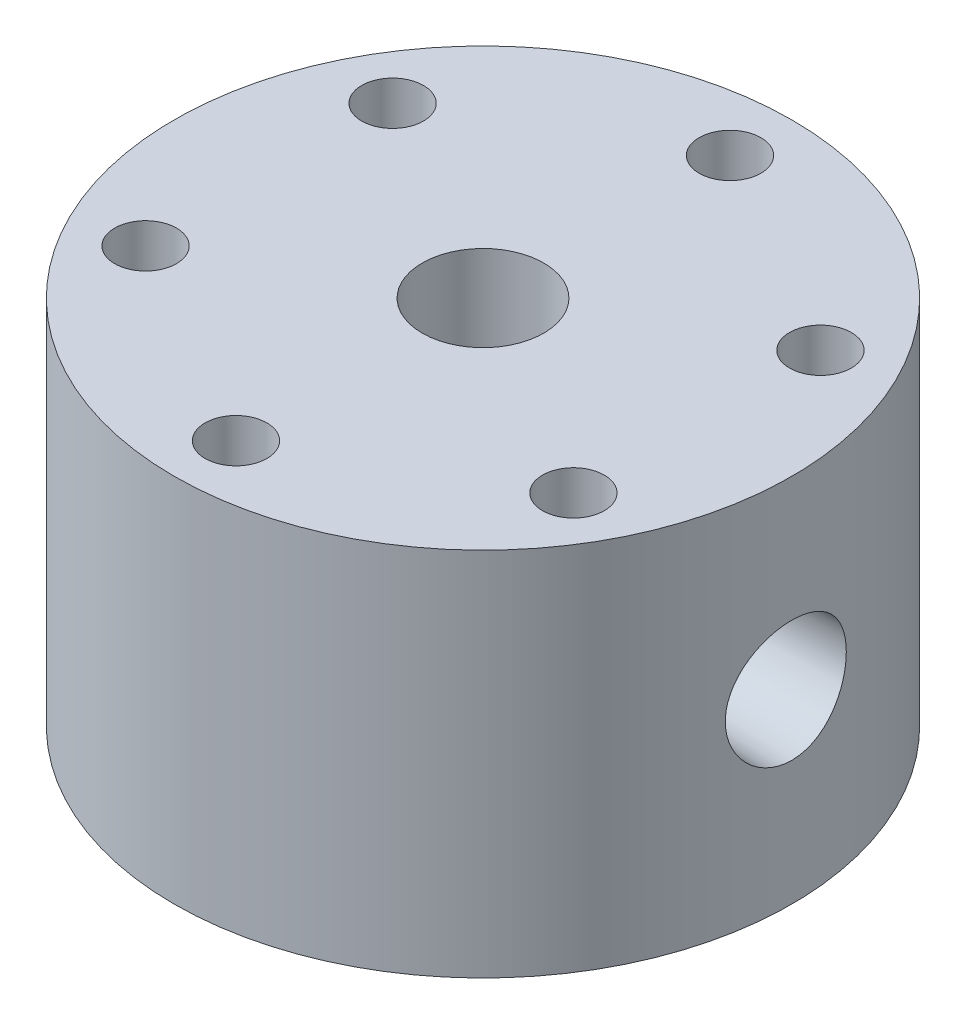
from build123d import *

# Parameters (mm, degrees)
M14X1_5_TAPPED_HOLE1_D              = 12.5
M14X1_5_TAPPED_HOLE1_DEPTH          = 25.4
M14X1_5_TAPPED_HOLE1_TIP            = 3.755378869
F_1_16_0_0625_DIAMETER_HOLE1_D      = 1.5875
F_1_16_0_0625_DIAMETER_HOLE1_DEPTH  = 28.575
F_1_16_0_0625_DIAMETER_HOLE1_TIP    = 0.476933116
F_3_32_0_09375_DIAMETER_HOLE1_D     = 2.38125
F_3_32_0_09375_DIAMETER_HOLE1_DEPTH = 28.702
F_3_32_0_09375_DIAMETER_HOLE1_TIP   = 0.715399675
F_1_4_0_25_DIAMETER_HOLE1_D         = 6.35
CIRPATTERN1_COUNT                   = 6
F_1_32_0_03125_DIAMETER_HOLE1_D     = 0.79375
F_1_32_0_03125_DIAMETER_HOLE1_DEPTH = 28.575
F_1_32_0_03125_DIAMETER_HOLE1_TIP   = 0.238466558


with BuildPart() as part:
    # Sketch1 → Revolve1 (revolve)
    with BuildSketch(Plane.XY):
        Polygon((-12.7, 0), (-31.75, 0), (-31.75, 38.1), (-3.81, 38.1), (-3.81, 6.35), (-8.0645, 6.35), (-8.0645, 8.382), (-11.1125, 8.382), (-11.1125, 6.35), (-12.7, 6.35), align=None)
    revolve(axis=Axis((0, 0, 0), (0, 1, 0)))

    # M14x1.5 Tapped Hole1
    with Locations(Plane(origin=(0, 38.1, 0), x_dir=(1, 0, 0), z_dir=(0, 1, 0))):
        with Locations((0, 0)):
            Hole(M14X1_5_TAPPED_HOLE1_D / 2, depth=M14X1_5_TAPPED_HOLE1_DEPTH)
            with Locations((0, 0, -(M14X1_5_TAPPED_HOLE1_DEPTH + M14X1_5_TAPPED_HOLE1_TIP / 2))):  # 118° drill point
                Cone(0, M14X1_5_TAPPED_HOLE1_D / 2, M14X1_5_TAPPED_HOLE1_TIP, mode=Mode.SUBTRACT)

    # Sketch6 → 1/4 NPT Tapped Hole1 (revolve, cut)
    with BuildSketch(Plane(origin=(31.75, 19.05, 0), x_dir=(0, 0, -1), z_dir=(0, 1, 0))):
        Polygon((0, 0), (0, 20.360347279), (5.5626, 17.018), (5.5626, 9.906), (5.943685794, 9.906), (6.2402847, 0), align=None)
    revolve(axis=Axis((38.1, 19.05, 0), (-1, 0, 0)), mode=Mode.SUBTRACT)

    # Sketch8 → 1/4 NPT Tapped Hole2 (revolve, cut)
    with BuildSketch(Plane(origin=(-31.75, 19.05, 0), x_dir=(0, 0, 1), z_dir=(0, 1, 0))):
        Polygon((0, 0), (0, 20.360347279), (5.5626, 17.018), (5.5626, 9.906), (5.943685794, 9.906), (6.2402847, 0), align=None)
    revolve(axis=Axis((-38.1, 19.05, 0), (1, 0, 0)), mode=Mode.SUBTRACT)

    # 1/16 (0.0625) Diameter Hole1
    with Locations(Plane(origin=(31.75, 0, 0), x_dir=(0, 0, -1), z_dir=(1, 0, 0))):
        with Locations((0, 19.05)):
            Hole(F_1_16_0_0625_DIAMETER_HOLE1_D / 2, depth=F_1_16_0_0625_DIAMETER_HOLE1_DEPTH)
            with Locations((0, 0, -(F_1_16_0_0625_DIAMETER_HOLE1_DEPTH + F_1_16_0_0625_DIAMETER_HOLE1_TIP / 2))):  # 118° drill point
                Cone(0, F_1_16_0_0625_DIAMETER_HOLE1_D / 2, F_1_16_0_0625_DIAMETER_HOLE1_TIP, mode=Mode.SUBTRACT)

    # 3/32 (0.09375) Diameter Hole1
    with Locations(Plane.ZY.offset(31.75)):
        with Locations((0, 19.05)):
            Hole(F_3_32_0_09375_DIAMETER_HOLE1_D / 2, depth=F_3_32_0_09375_DIAMETER_HOLE1_DEPTH)
            with Locations((0, 0, -(F_3_32_0_09375_DIAMETER_HOLE1_DEPTH + F_3_32_0_09375_DIAMETER_HOLE1_TIP / 2))):  # 118° drill point
                Cone(0, F_3_32_0_09375_DIAMETER_HOLE1_D / 2, F_3_32_0_09375_DIAMETER_HOLE1_TIP, mode=Mode.SUBTRACT)

    # 1/4 (0.25) Diameter Hole1 (through all)
    with Locations(Plane(origin=(0, 38.1, 0), x_dir=(1, 0, 0), z_dir=(0, 1, 0))):
        with Locations((21.997045256, 12.7)):
            f_1_4_0_25_diameter_hole1 = Hole(F_1_4_0_25_DIAMETER_HOLE1_D / 2)

    # CirPattern1: 1/4 (0.25) Diameter Hole1 ×6 about axis
    cirpattern1_axis = Axis((0, 0, 0), (0, 1, 0))
    for i in range(1, CIRPATTERN1_COUNT):
        add(f_1_4_0_25_diameter_hole1.rotate(cirpattern1_axis, i * 360 / CIRPATTERN1_COUNT), mode=Mode.SUBTRACT)

    # Sketch18 → 1/4 NPT Tapped Hole3 (revolve, cut)
    with BuildSketch(Plane(origin=(15.875, 19.05, -27.49630657), x_dir=(-0.866025404, 0, -0.5), z_dir=(0, 1, 0))):
        Polygon((0, 0), (0, 20.360347279), (5.5626, 17.018), (5.5626, 9.906), (5.943685794, 9.906), (6.2402847, 0), align=None)
    revolve(axis=Axis((19.05, 19.05, -32.995567884), (-0.5, 0, 0.866025404)), mode=Mode.SUBTRACT)

    # 1/32 (0.03125) Diameter Hole1
    with Locations(Plane(origin=(15.875, 0, -27.49630657), x_dir=(0, -1, 0), z_dir=(0.5, 0, -0.866025404))):
        with Locations((-19.05, 0)):
            Hole(F_1_32_0_03125_DIAMETER_HOLE1_D / 2, depth=F_1_32_0_03125_DIAMETER_HOLE1_DEPTH)
            with Locations((0, 0, -(F_1_32_0_03125_DIAMETER_HOLE1_DEPTH + F_1_32_0_03125_DIAMETER_HOLE1_TIP / 2))):  # 118° drill point
                Cone(0, F_1_32_0_03125_DIAMETER_HOLE1_D / 2, F_1_32_0_03125_DIAMETER_HOLE1_TIP, mode=Mode.SUBTRACT)


solid = part.part
